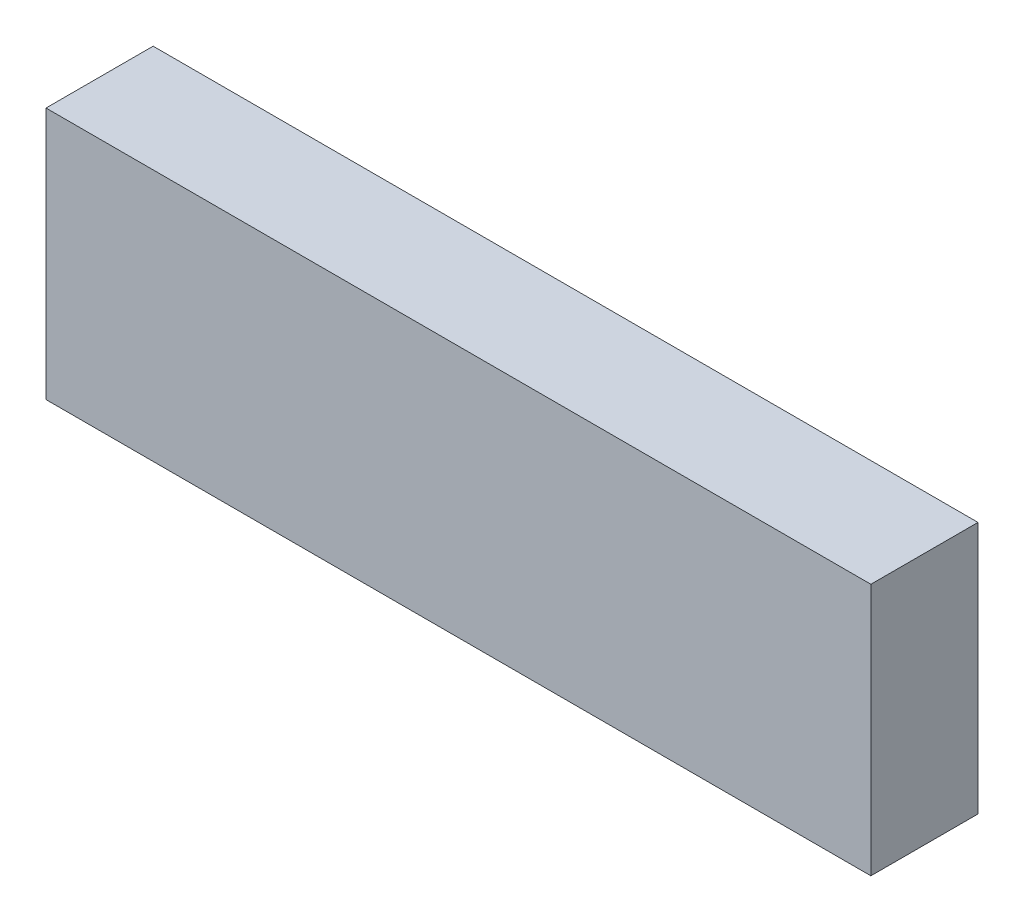
from build123d import *

# Parameters (mm, degrees)
SKETCH1_W           = 136.906
SKETCH1_H           = 41.91
BOSS_EXTRUDE1_DEPTH = 17.78


with BuildPart() as part:
    # Sketch1 → Boss-Extrude1 (new body)
    with BuildSketch(Plane.XY):
        Rectangle(SKETCH1_W, SKETCH1_H)
    extrude(amount=BOSS_EXTRUDE1_DEPTH)


solid = part.part
